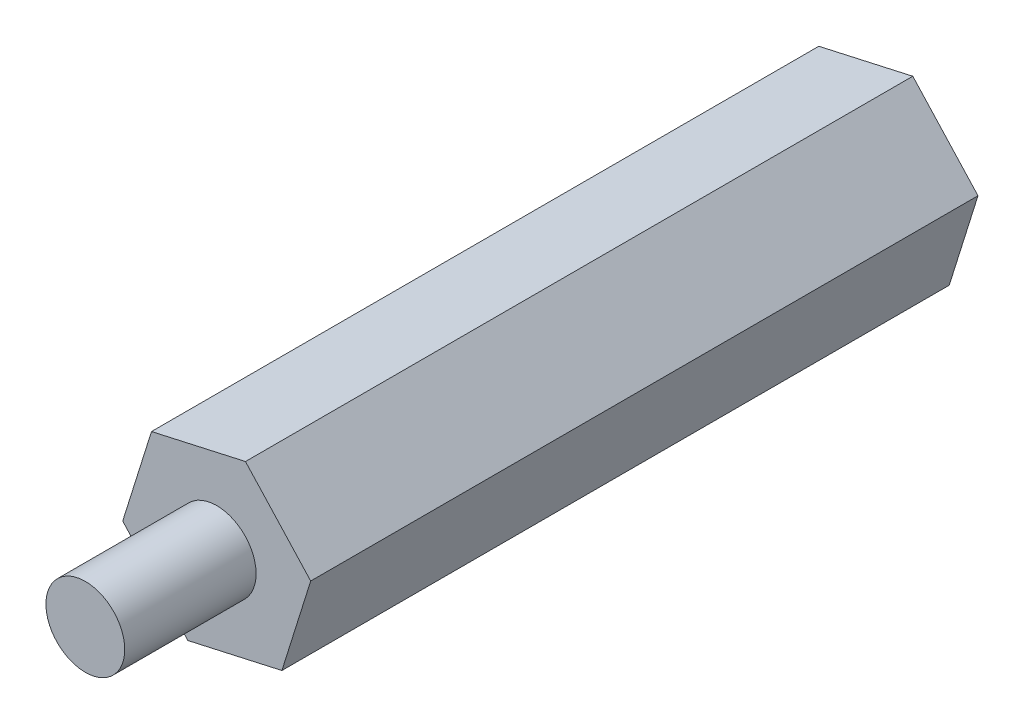
from build123d import *

# Parameters (mm, degrees)
SKETCH1_R           = 1.5
BOSS_EXTRUDE1_DEPTH = 25.4
SKETCH2_R           = 1.5
BOSS_EXTRUDE2_DEPTH = 5


with BuildPart() as part:
    # Sketch1 → Boss-Extrude1 (new body)
    with BuildSketch(Plane.XY):
        Polygon((2.482034315, -2.698210331), (3.577735849, 0.800399604), (1.095701534, 3.498609936), (-2.482034315, 2.698210331), (-3.577735849, -0.800399604), (-1.095701534, -3.498609936), align=None)
        Circle(SKETCH1_R, mode=Mode.SUBTRACT)
    extrude(amount=BOSS_EXTRUDE1_DEPTH)


with BuildPart() as body_2:
    # Sketch2 → Boss-Extrude2 (new body)
    with BuildSketch(Plane.XY.offset(25.4)):
        Circle(SKETCH2_R)
    extrude(amount=BOSS_EXTRUDE2_DEPTH)


solid = Compound([part.part, body_2.part])
